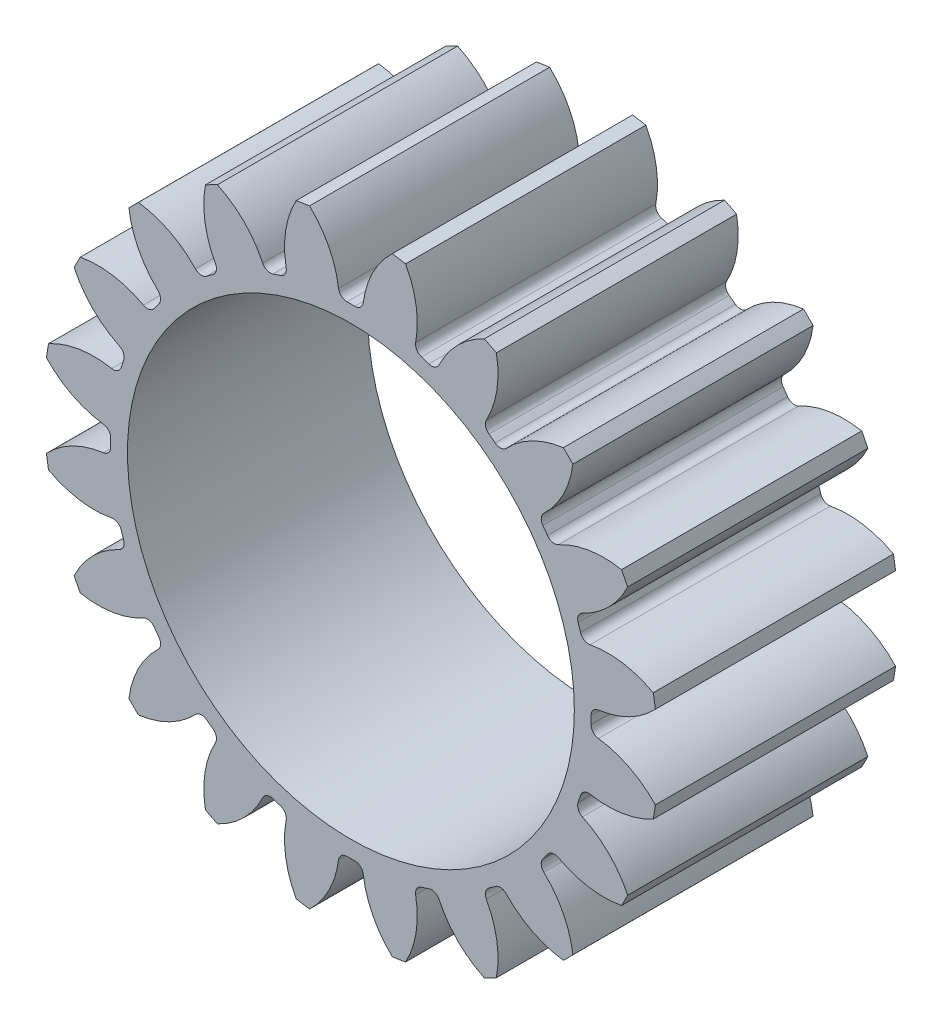
from build123d import *

# Parameters (mm, degrees)
SKETCH1_R                = 5.5
BOSS_EXTRUDE1_DEPTH      = 2.15
CUT_EXTRUDE1_DEPTH       = 9.0698513
FILLET1_R                = 0.15
CIRPATTERN1_COUNT        = 20
FILLET1_OF_CIRPATTERN1_R = 0.15
CUT_EXTRUDE2_DEPTH       = 9.001546002
CUT_EXTRUDE2_DEPTH_BACK  = 9.001546002
SKETCH2_R                = 4


with BuildPart() as part:
    # Sketch1 → Boss-Extrude1 (new, symmetric)
    with BuildSketch(Plane.XY):
        Circle(SKETCH1_R)
    extrude(amount=BOSS_EXTRUDE1_DEPTH, both=True)

    # Gear Profile → Cut-Extrude1 (cut, symmetric)
    with BuildSketch(Plane.XY):
        with BuildLine():
            ThreePointArc((-1.397438526, 5.834994907), (-0.561298831, 5.251618442), (-0.208890253, 4.29492315))
            ThreePointArc((-0.208890253, 4.29492315), (0, 4.3), (0.208890253, 4.29492315))
            ThreePointArc((0.208890253, 4.29492315), (0.561298831, 5.251618442), (1.397438526, 5.834994907))
            ThreePointArc((1.397438526, 5.834994907), (0, 6), (-1.397438526, 5.834994907))
        make_face()
    cut_extrude1 = extrude(amount=CUT_EXTRUDE1_DEPTH, both=True, mode=Mode.SUBTRACT)

    # Fillet1
    fillet1_edges = [part.edges().sort_by_distance(p)[0] for p in [
        (0.208890253, 4.29492315, 0),
        (-0.208890253, 4.29492315, 0),
    ]]
    fillet(fillet1_edges, radius=FILLET1_R)

    # CirPattern1: Cut-Extrude1 ×20 about axis
    cirpattern1_axis = Axis((0, 0, -2.75), (0, 0, 1))
    for i in range(1, CIRPATTERN1_COUNT):
        add(cut_extrude1.rotate(cirpattern1_axis, i * 360 / CIRPATTERN1_COUNT), mode=Mode.SUBTRACT)

    # Fillet1 of CirPattern1
    fillet1_of_cirpattern1_edges = [part.edges().sort_by_distance(p)[0] for p in [
        (-1.128537806, 4.149265287, 0),
        (-1.525870679, 4.02016401, 0),
        (-2.355496722, 3.597448428, 0),
        (-2.693488252, 3.351883208, 0),
        (-3.351883208, 2.693488252, 0),
        (-3.597448428, 2.355496722, 0),
        (-4.02016401, 1.525870679, 0),
        (-4.149265287, 1.128537806, 0),
        (-4.29492315, 0.208890253, 0),
        (-4.29492315, -0.208890253, 0),
        (-4.149265287, -1.128537806, 0),
        (-4.02016401, -1.525870679, 0),
        (-3.597448428, -2.355496722, 0),
        (-3.351883208, -2.693488252, 0),
        (-2.693488252, -3.351883208, 0),
        (-2.355496722, -3.597448428, 0),
        (-1.525870679, -4.02016401, 0),
        (-1.128537806, -4.149265287, 0),
        (-0.208890253, -4.29492315, 0),
        (0.208890253, -4.29492315, 0),
        (1.128537806, -4.149265287, 0),
        (1.525870679, -4.02016401, 0),
        (2.355496722, -3.597448428, 0),
        (2.693488252, -3.351883208, 0),
        (3.351883208, -2.693488252, 0),
        (3.597448428, -2.355496722, 0),
        (4.02016401, -1.525870679, 0),
        (4.149265287, -1.128537806, 0),
        (4.29492315, -0.208890253, 0),
        (4.29492315, 0.208890253, 0),
        (4.149265287, 1.128537806, 0),
        (4.02016401, 1.525870679, 0),
        (3.597448428, 2.355496722, 0),
        (3.351883208, 2.693488252, 0),
        (2.693488252, 3.351883208, 0),
        (2.355496722, 3.597448428, 0),
        (1.525870679, 4.02016401, 0),
        (1.128537806, 4.149265287, 0),
    ]]
    fillet(fillet1_of_cirpattern1_edges, radius=FILLET1_OF_CIRPATTERN1_R)

    # Sketch2 → Cut-Extrude2 (cut, two sides: drawn at the far end of the back side and taken through both)
    with BuildSketch(Plane.XY.offset(-CUT_EXTRUDE2_DEPTH_BACK)):
        Circle(SKETCH2_R)
    extrude(amount=CUT_EXTRUDE2_DEPTH + CUT_EXTRUDE2_DEPTH_BACK, mode=Mode.SUBTRACT)


solid = part.part
